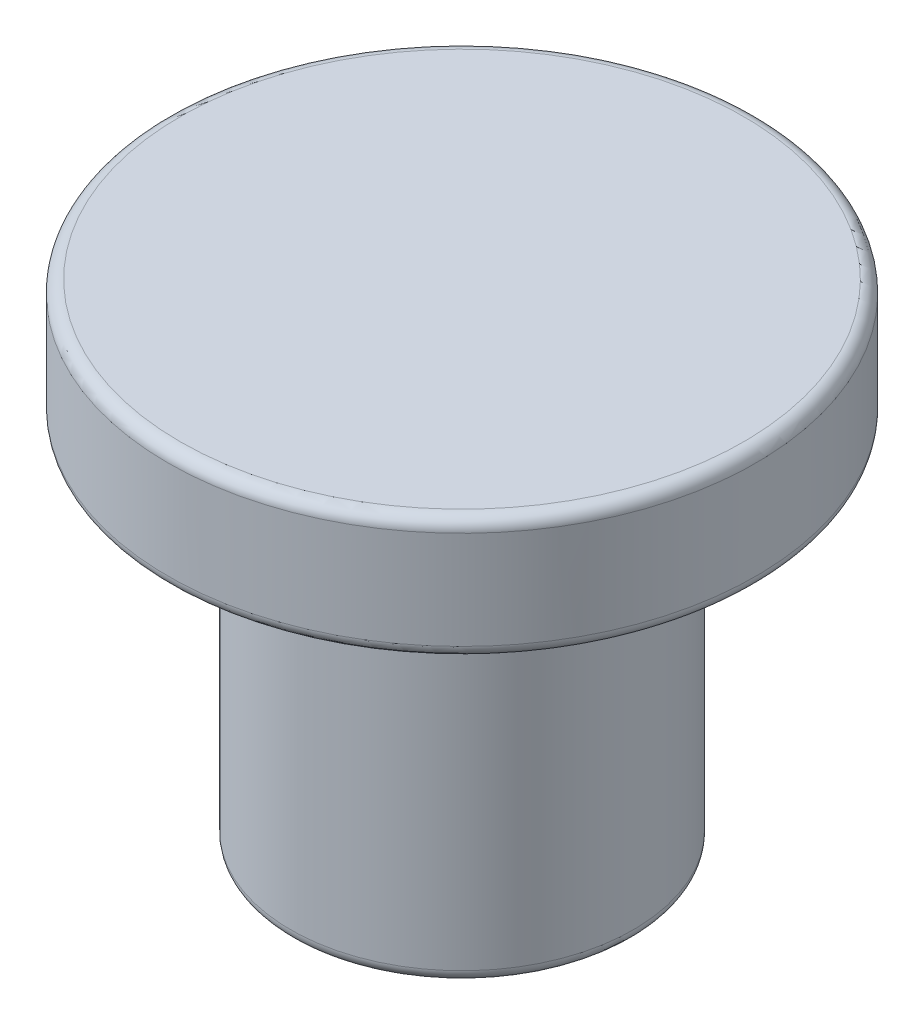
from build123d import *

# Parameters (mm, degrees)
FILETE1_R = 0.5


with BuildPart() as part:
    # Esboço1 → Revolução1 (revolve)
    with BuildSketch(Plane.XY, mode=Mode.PRIVATE) as revolu_o1_sk:
        Polygon((0, 0), (0, 20), (12, 20), (12, 15), (7, 15), (7, 0), align=None)
    revolve(revolu_o1_sk.sketch.rotate(Axis((0, 0, 0), (0, 1, 0)), 90), axis=Axis((0, 0, 0), (0, 1, 0)))  # turned: the seam where the file's is

    # Filete1
    filete1_edges = [part.edges().sort_by_distance(p)[0] for p in [
        (0, 0, 7),
        (0, 15, 12),
        (0, 20, 12),
    ]]
    fillet(filete1_edges, radius=FILETE1_R)


solid = part.part
